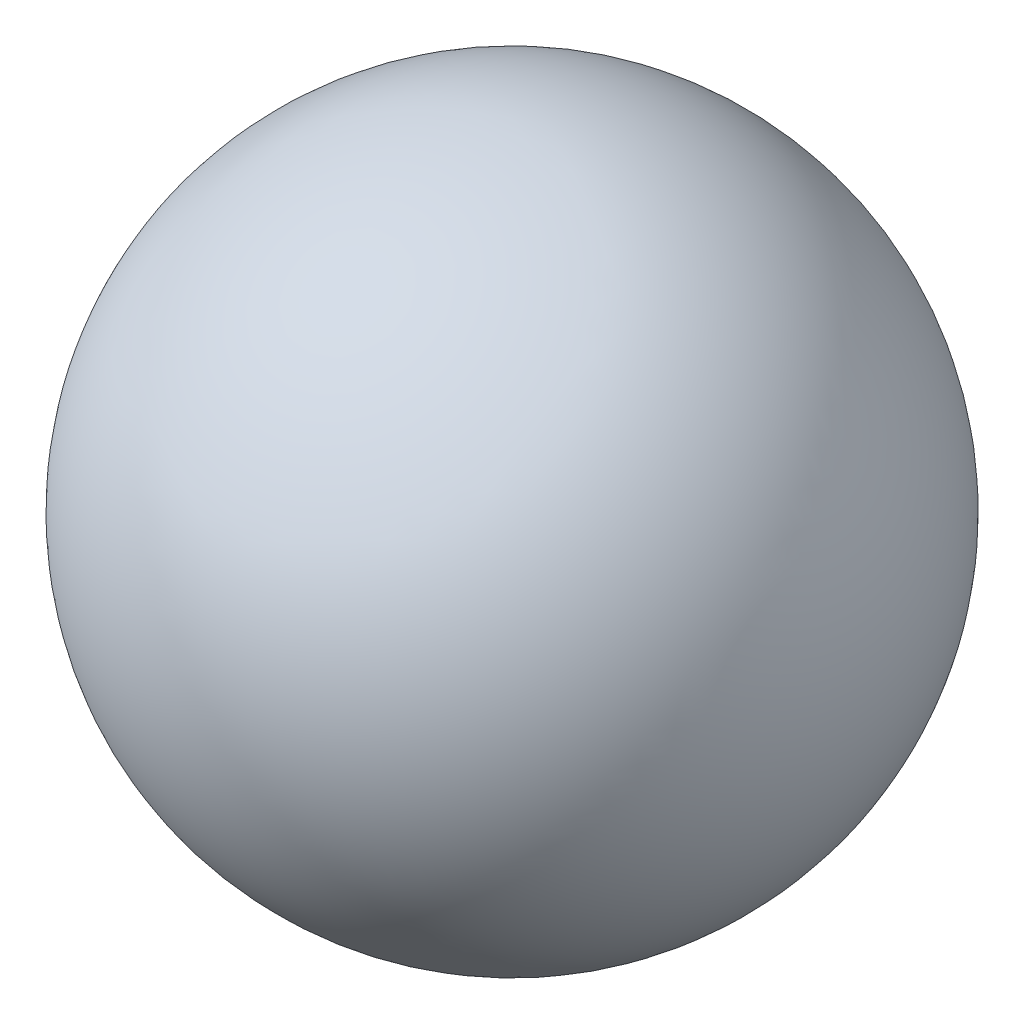
from build123d import *


with BuildPart() as part:
    # Sketch1 → Revolve1 (revolve)
    with BuildSketch(Plane.XY.offset(3.827)):
        with BuildLine():
            Line((12.882, 9.239), (8.118, 9.239))
            ThreePointArc((8.118, 9.239), (10.5, 11.621), (12.882, 9.239))
        make_face()
    revolve(axis=Axis((50, 9.239, 3.827), (-1, 0, 0)))


solid = part.part
